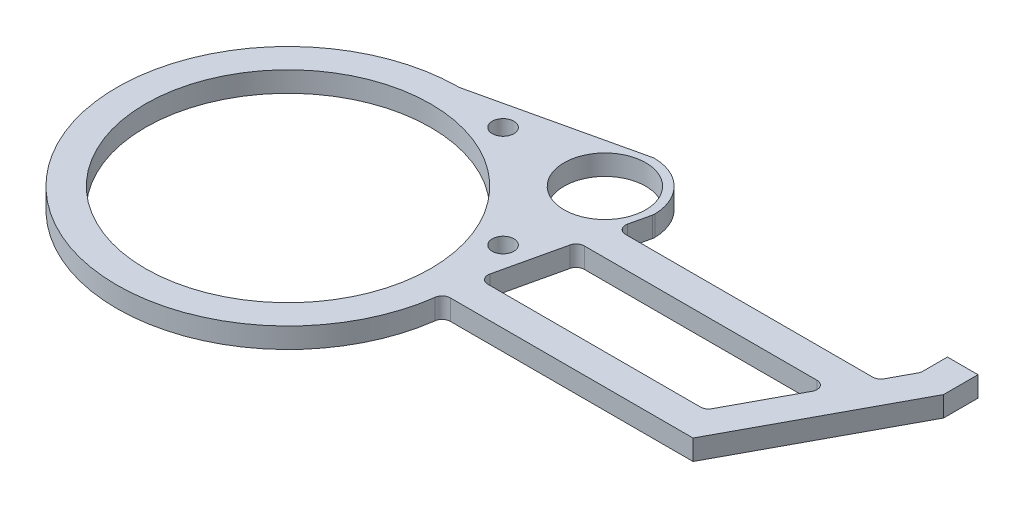
from build123d import *

# Parameters (mm, degrees)
BOSS_EXTRUDE1_DEPTH             = 6.35
FILLET2_R                       = 6.35
BOSS_EXTRUDE2_DEPTH             = 6.35
SKETCH3_R                       = 44.4754
SKETCH3_R_2                     = 12.7254
CUT_EXTRUDE1_DEPTH              = 7.35
FILLET3_R                       = 2.54
F_6_32_TAPPED_HOLE1_D           = 2.7051
F_6_32_TAPPED_HOLE1_DEPTH       = 9.398
F_6_32_TAPPED_HOLE1_CBORE_D     = 3.5052
F_6_32_TAPPED_HOLE1_CBORE_DEPTH = 7.112
F_6_32_TAPPED_HOLE1_TIP         = 0.81269403
F_1_4_CLEARANCE_HOLE1_D         = 6.7564
F_1_4_CLEARANCE_HOLE1_DEPTH     = 25.4
F_1_4_CLEARANCE_HOLE1_TIP       = 2.029827343


with BuildPart() as part:
    # Sketch1 → Boss-Extrude1 (new body)
    with BuildSketch(Plane(origin=(0, 0, 0), x_dir=(1, 0, 0), z_dir=(0, 1, 0))):
        with BuildLine():
            Line((0, 53.3781), (49.391408666, 64.669508666))
            ThreePointArc((49.391408666, 64.669508666), (60.19465678, 60.19465678), (64.669508666, 49.391408666))
            Line((64.669508666, 49.391408666), (53.3781, 0))
            ThreePointArc((53.3781, 0), (-37.744016477, -37.744016477), (0, 53.3781))
        make_face()
    extrude(amount=BOSS_EXTRUDE1_DEPTH)

    # Fillet2
    fillet2_edges = [part.edges().sort_by_distance(p)[0] for p in [
        (0, 3.175, -53.3781),
        (53.3781, 3.175, 0),
    ]]
    fillet(fillet2_edges, radius=FILLET2_R)

    # Sketch4 → Boss-Extrude2 (add)
    with BuildSketch(Plane(origin=(0, 6.35, 0), x_dir=(1, 0, 0), z_dir=(0, 1, 0))):
        Polygon((52.07, -4.84480564), (131.116478857, -4.84480564), (158.4325, 45.95519436), (158.4325, 56.6794421), (148.9075, 56.6794421), (148.9075, 48.353689839), (144.203285679, 39.60519436), (52.07, 39.60519436), (52.07, 30.08019436), (139.081531715, 30.08019436), (125.423521143, 4.68019436), (52.07, 4.68019436), align=None)
    extrude(amount=-BOSS_EXTRUDE2_DEPTH)

    # Sketch3 → Cut-Extrude1 (cut, through all)
    with BuildSketch(Plane(origin=(0, 6.35, 0), x_dir=(1, 0, 0), z_dir=(0, 1, 0))):
        Circle(SKETCH3_R)
        with Locations((49.391408666, 49.391408666)):
            Circle(SKETCH3_R_2)
    extrude(amount=-CUT_EXTRUDE1_DEPTH, mode=Mode.SUBTRACT)

    # Fillet3
    fillet3_edges = [part.edges().sort_by_distance(p)[0] for p in [
        (139.081531715, 3.175, -30.08019436),
        (54.448042903, 3.175, -4.68019436),
        (125.423521143, 3.175, -4.68019436),
        (60.25475682, 3.175, -30.08019436),
        (62.432274539, 3.175, -39.60519436),
        (144.203285679, 3.175, -39.60519436),
        (148.9075, 3.175, -48.353689839),
        (53.157778527, 3.175, 4.84480564),
        (49.391408666, 3.175, -64.669508666),
        (64.669508666, 3.175, -49.391408666),
    ]]
    fillet(fillet3_edges, radius=FILLET3_R)

    # #6-32 Tapped Hole1
    with Locations(Plane(origin=(0, 0, -56.6794421), x_dir=(-1, 0, 0), z_dir=(0, 0, -1))):
        with Locations((-153.67, 3.175)):
            CounterBoreHole(F_6_32_TAPPED_HOLE1_D / 2, F_6_32_TAPPED_HOLE1_CBORE_D / 2, F_6_32_TAPPED_HOLE1_CBORE_DEPTH, depth=F_6_32_TAPPED_HOLE1_DEPTH)
            with Locations((0, 0, -(F_6_32_TAPPED_HOLE1_DEPTH + F_6_32_TAPPED_HOLE1_TIP / 2))):  # 118° drill point
                Cone(0, F_6_32_TAPPED_HOLE1_D / 2, F_6_32_TAPPED_HOLE1_TIP, mode=Mode.SUBTRACT)

    # 1/4 Clearance Hole1
    with Locations(Plane.XZ):
        with Locations((49.391408666, -17.641408666), (17.641408666, -49.391408666)):
            Hole(F_1_4_CLEARANCE_HOLE1_D / 2, depth=F_1_4_CLEARANCE_HOLE1_DEPTH)
            with Locations((0, 0, -(F_1_4_CLEARANCE_HOLE1_DEPTH + F_1_4_CLEARANCE_HOLE1_TIP / 2))):  # 118° drill point
                Cone(0, F_1_4_CLEARANCE_HOLE1_D / 2, F_1_4_CLEARANCE_HOLE1_TIP, mode=Mode.SUBTRACT)


solid = part.part
